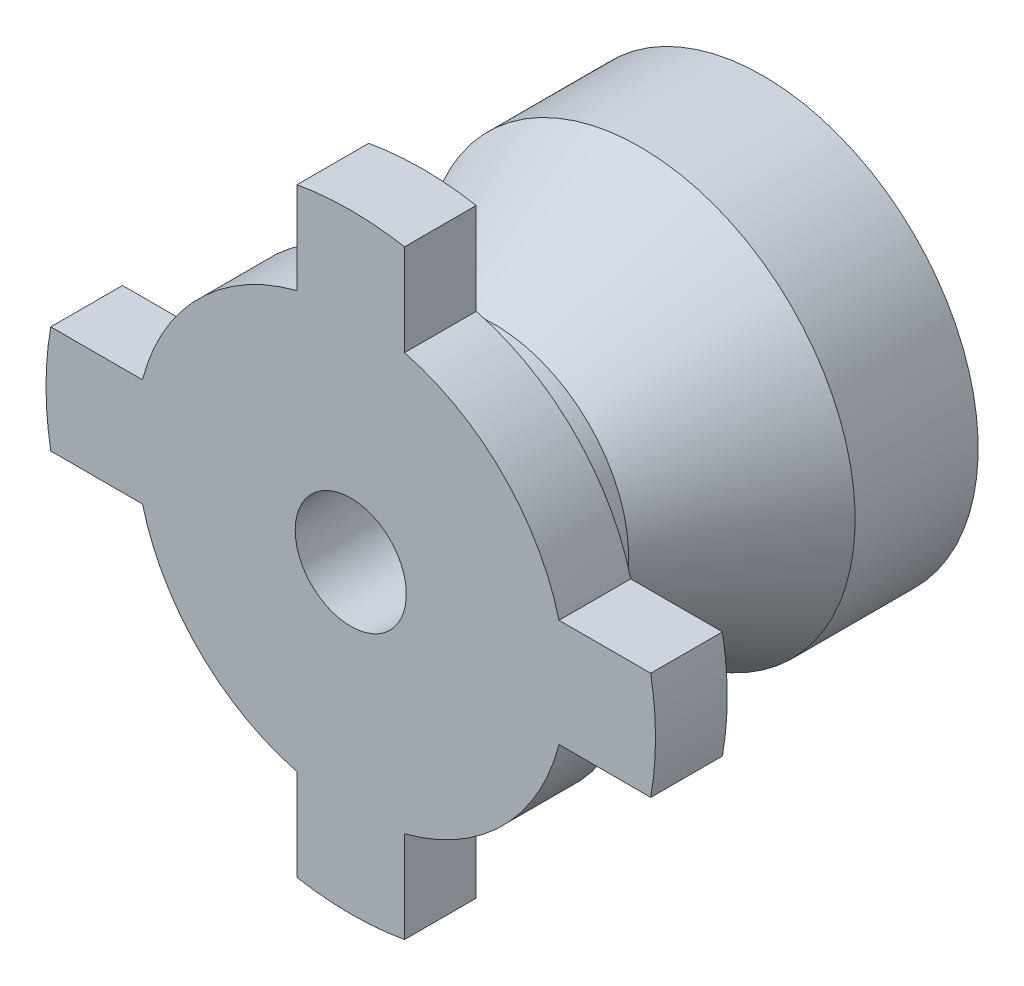
from build123d import *

# Parameters (mm, degrees)
BOSS_EXTRUDE1_DEPTH = 2


with BuildPart() as part:
    # Sketch1 → Revolve1 (revolve)
    with BuildSketch(Plane(origin=(0, 0, 0), x_dir=(1, 0, 0), z_dir=(0, 1, 0))):
        Polygon((-1.55, 0), (-6, 0), (-6, 2), (-3.75, 2), (-3.75, 4), (-6, 8.067249704), (-6, 11.5), (-5, 11.5), (-5, 9), (-2.688359629, 9), (-2.688359629, 7.5), (-1.55, 7.5), align=None)
    revolve(axis=Axis((0, 0, -14.260315956), (0, 0, 1)))

    # Sketch2 → Boss-Extrude1 (add)
    with BuildSketch(Plane.XY):
        with BuildLine():
            Line((-8.366600265, 1.5), (-5.809475019, 1.5))
            ThreePointArc((-5.809475019, 1.5), (-6, 0), (-5.809475019, -1.5))
            Line((-5.809475019, -1.5), (-8.366600265, -1.5))
            ThreePointArc((-8.366600265, -1.5), (-8.5, 0), (-8.366600265, 1.5))
        make_face()
        with BuildLine():
            Line((1.5, 8.366600265), (1.5, 5.809475019))
            ThreePointArc((1.5, 5.809475019), (0, 6), (-1.5, 5.809475019))
            Line((-1.5, 5.809475019), (-1.5, 8.366600265))
            ThreePointArc((-1.5, 8.366600265), (0, 8.5), (1.5, 8.366600265))
        make_face()
        with BuildLine():
            Line((8.366600265, -1.5), (5.809475019, -1.5))
            ThreePointArc((5.809475019, -1.5), (6, 0), (5.809475019, 1.5))
            Line((5.809475019, 1.5), (8.366600265, 1.5))
            ThreePointArc((8.366600265, 1.5), (8.5, 0), (8.366600265, -1.5))
        make_face()
        with BuildLine():
            Line((-1.5, -8.366600265), (-1.5, -5.809475019))
            ThreePointArc((-1.5, -5.809475019), (0, -6), (1.5, -5.809475019))
            Line((1.5, -5.809475019), (1.5, -8.366600265))
            ThreePointArc((1.5, -8.366600265), (0, -8.5), (-1.5, -8.366600265))
        make_face()
    extrude(amount=-BOSS_EXTRUDE1_DEPTH)


solid = part.part
